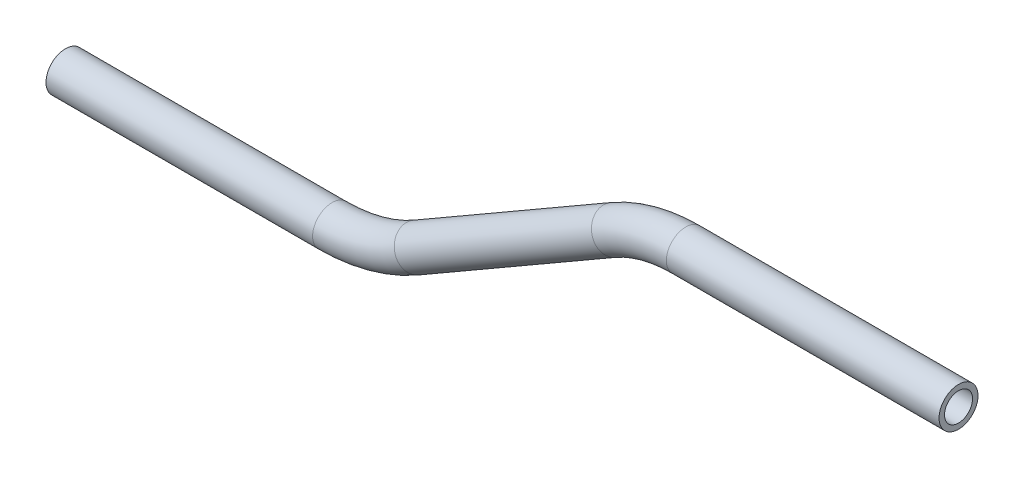
from build123d import *

# Parameters (mm, degrees)
SKETCH2_R   = 3.175
SKETCH2_R_2 = 2.286


with BuildPart() as part:
    # Sweep1: sweep along a path in Sketch1
    with BuildLine(Plane.XY) as sweep1_path:
        Line((44.460002734, 0), (0, 0))
        ThreePointArc((0, 0), (-6.123967098, -0.806235564), (-11.830595958, -3.169998633))
        Line((-11.830595958, -3.169998633), (-43.979259883, -21.731038404))
        ThreePointArc((-43.979259883, -21.731038404), (-50.584121448, -24.466861642), (-57.67201097, -25.4))
        Line((-57.67201097, -25.4), (-101.134087778, -25.4))
    # Sketch2 → Sweep1 (sweep)
    with BuildSketch(Plane(origin=(44.460002734, 0, 0), x_dir=(0, 0, -1), z_dir=(1, 0, 0))):
        Circle(SKETCH2_R)
        Circle(SKETCH2_R_2, mode=Mode.SUBTRACT)
    sweep(path=sweep1_path.line)


solid = part.part
